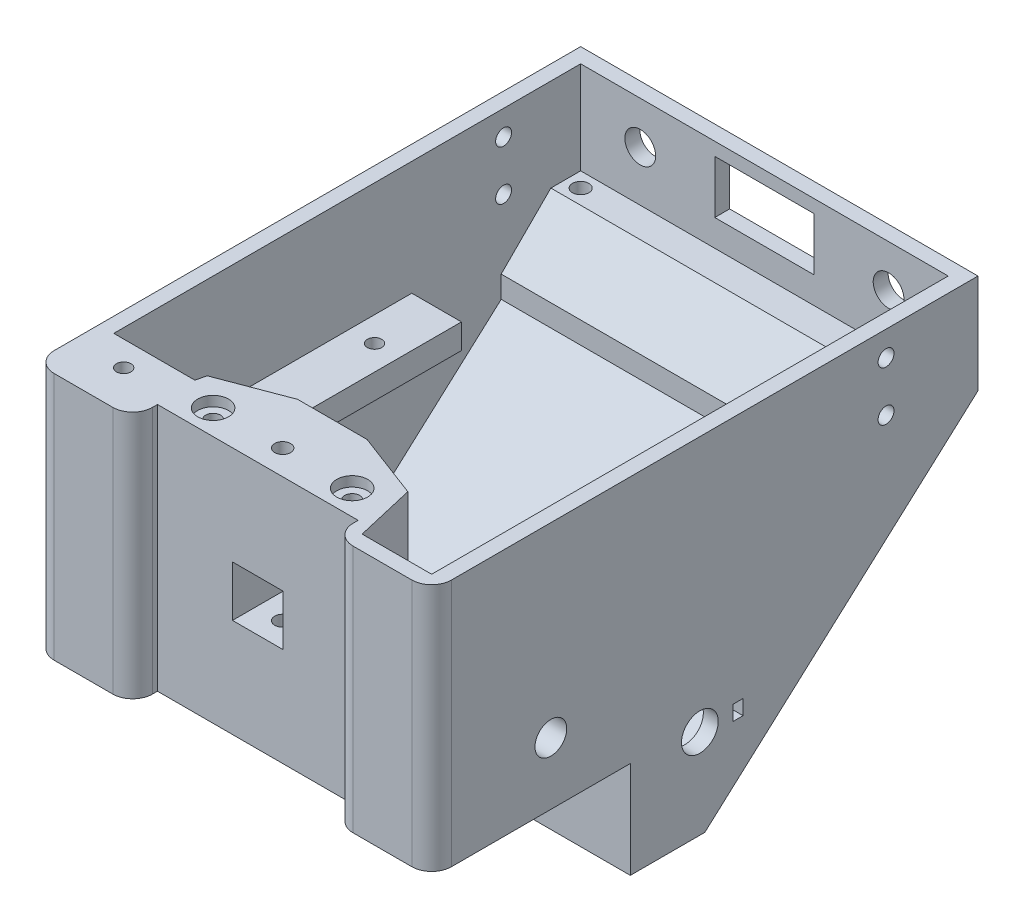
from build123d import *

# Parameters (mm, degrees)
BOSS_EXTRUDE1_DEPTH      = 80
SHELL1_T                 = -3
SKETCH3_W                = 46
SKETCH3_H                = 47
BOSS_EXTRUDE2_DEPTH      = 17
SKETCH4_W                = 10.2
SKETCH4_H                = 10.2
CUT_EXTRUDE1_DEPTH       = 20
SKETCH6_W                = 15
SKETCH6_H                = 12.8
CUT_EXTRUDE2_DEPTH       = 3
SKETCH7_W                = 40.4
SKETCH7_H                = 50
CUT_EXTRUDE3_DEPTH       = 5
FILLET1_R                = 4
CUT_EXTRUDE7_DEPTH       = 47
SKETCH13_R               = 1.5
CUT_EXTRUDE8_DEPTH       = 25
SKETCH14_R               = 3.1
CUT_EXTRUDE9_DEPTH       = 2
SKETCH17_W               = 45
SKETCH17_H               = 5
BOSS_EXTRUDE5_DEPTH      = 74
CUT_EXTRUDE10_REACH      = 126.093
SKETCH18_W               = 54
SKETCH18_H               = 45
CUT_EXTRUDE11_REACH      = 126.093
SKETCH19_R               = 1.45
BOSS_EXTRUDE6_DEPTH      = 47
SKETCH22_R               = 1.45
CUT_EXTRUDE12_DEPTH      = 135.415364765
CUT_EXTRUDE13_REACH      = 126.857
SKETCH24_R               = 3.7
SKETCH24_W               = 2
SKETCH24_H               = 3
BOSS_EXTRUDE7_DEPTH      = 74
SKETCH27_R               = 1.65
CUT_EXTRUDE14_DEPTH      = 10
CUT_EXTRUDE15_START      = -3
CUT_EXTRUDE15_DEPTH      = 32
CUT_EXTRUDE16_DEPTH      = 30
BOSS_EXTRUDE8_DEPTH      = 20
SKETCH31_R               = 1.5
CUT_EXTRUDE17_DEPTH      = 123.649786567
CUT_EXTRUDE18_DEPTH      = 15
CUT_EXTRUDE19_REACH      = 126.093
SKETCH33_W               = 10
SKETCH33_H               = 5
SKETCH34_R               = 1.6
CUT_EXTRUDE20_DEPTH      = 135.415364765
CUT_EXTRUDE22_DEPTH      = 14
CUT_EXTRUDE23_REACH      = 126.857
SKETCH37_R               = 3.2
SKETCH38_W               = 10
SKETCH38_H               = 18.980735551
SKETCH38_R               = 3.2
BOSS_EXTRUDE9_DEPTH      = 3
CUT_EXTRUDE24_REACH      = 124.956
SKETCH40_R               = 3.7
SKETCH40_W               = 2
SKETCH40_H               = 3
SKETCH41_R               = 1.6
CUT_EXTRUDE25_DEPTH      = 123.956316006
CUT_EXTRUDE25_DEPTH_BACK = 123.956316006
SKETCH43_W               = 20
SKETCH43_H               = 10.67
CUT_EXTRUDE26_DEPTH      = 3
CHAMFER1_SIZE            = 10
SKETCH44_R               = 3.1
CUT_EXTRUDE27_DEPTH      = 143.134986308


with BuildPart() as part:
    # Sketch2 → Boss-Extrude1 (new body)
    with BuildSketch(Plane(origin=(0, 0, 0), x_dir=(0, 0, -1), z_dir=(1, 0, 0))):
        Polygon((-27.320490368, 20.998248687), (-27.320490368, -29.001751313), (12.679509632, -29.001751313), (12.679509632, -48.511383538), (27.679509632, -48.511383538), (82.679509632, 0.998248687), (82.679509632, 20.998248687), align=None)
    extrude(amount=BOSS_EXTRUDE1_DEPTH)

    # Shell1
    shell1_openings = [part.faces().sort_by_distance(p)[0] for p in [
        (40, 20.998248687, -27.679509632),
    ]]
    offset(amount=SHELL1_T, openings=shell1_openings, kind=Kind.INTERSECTION)

    # Sketch3 → Boss-Extrude2 (add)
    with BuildSketch(Plane(origin=(0, 0, 24.320490368), x_dir=(-1, 0, 0), z_dir=(0, 0, -1))):
        with Locations((-40, -2.501751313)):
            Rectangle(SKETCH3_W, SKETCH3_H)
    extrude(amount=BOSS_EXTRUDE2_DEPTH)

    # Sketch4 → Cut-Extrude1 (cut)
    with BuildSketch(Plane.XY.offset(27.320490368)):
        with Locations((40, -4.001751313)):
            Rectangle(SKETCH4_W, SKETCH4_H)
    extrude(amount=-CUT_EXTRUDE1_DEPTH, mode=Mode.SUBTRACT)

    # Sketch6 → Cut-Extrude2 (cut)
    with BuildSketch(Plane.XZ.offset(29.001751313)):
        with Locations((40, 0.920490368)):
            Rectangle(SKETCH6_W, SKETCH6_H)
    extrude(amount=-CUT_EXTRUDE2_DEPTH, mode=Mode.SUBTRACT)

    # Sketch7 → Cut-Extrude3 (cut)
    with BuildSketch(Plane.XY.offset(27.320490368)):
        with Locations((40, -4.001751313)):
            Rectangle(SKETCH7_W, SKETCH7_H)
    extrude(amount=-CUT_EXTRUDE3_DEPTH, mode=Mode.SUBTRACT)

    # Fillet1
    fillet1_edges = [part.edges().sort_by_distance(p)[0] for p in [
        (80, -4.001751313, 27.320490368),
        (19.8, -4.001751313, 27.320490368),
        (0, -4.001751313, 27.320490368),
        (60.2, -4.001751313, 27.320490368),
    ]]
    fillet(fillet1_edges, radius=FILLET1_R)

    # Sketch12 → Cut-Extrude7 (cut)
    with BuildSketch(Plane(origin=(0, 20.998248687, 0), x_dir=(1, 0, 0), z_dir=(0, 1, 0))):
        Polygon((33, -7.320490368), (19.8, -12.320490368), (17, -24.320490368), (17, -7.320490368), align=None)
        Polygon((47, -7.320490368), (63, -7.320490368), (63, -24.320490368), (60.2, -12.320490368), align=None)
    extrude(amount=-CUT_EXTRUDE7_DEPTH, mode=Mode.SUBTRACT)

    # Sketch13 → Cut-Extrude8 (cut)
    with BuildSketch(Plane(origin=(0, 20.998248687, 0), x_dir=(1, 0, 0), z_dir=(0, 1, 0))):
        with Locations(Location((26, -17.320490368, 0), (0, 0, 270))):
            Circle(SKETCH13_R)
        with Locations(Location((54, -17.320490368, 0), (0, 0, 270))):
            Circle(SKETCH13_R)
    extrude(amount=-CUT_EXTRUDE8_DEPTH, mode=Mode.SUBTRACT)

    # Sketch14 → Cut-Extrude9 (cut)
    with BuildSketch(Plane(origin=(0, 20.998248687, 0), x_dir=(1, 0, 0), z_dir=(0, 1, 0))):
        with Locations(Location((26, -17.320490368, 0), (0, 0, 270))):
            Circle(SKETCH14_R)
        with Locations(Location((54, -17.320490368, 0), (0, 0, 270))):
            Circle(SKETCH14_R)
    extrude(amount=-CUT_EXTRUDE9_DEPTH, mode=Mode.SUBTRACT)

    # Sketch17 → Boss-Extrude5 (add)
    with BuildSketch(Plane.ZY.offset(-77)):
        with Locations((-23.179509632, -4.501751313)):
            Rectangle(SKETCH17_W, SKETCH17_H)
    extrude(amount=BOSS_EXTRUDE5_DEPTH)

    # Sketch18 → Cut-Extrude10 (cut, up to next)
    with BuildSketch(Plane(origin=(0, -2.001751313, 0), x_dir=(1, 0, 0), z_dir=(0, 1, 0)), mode=Mode.PRIVATE) as cut_extrude10_sk1:
        with Locations((40, 23.179509632)):
            Rectangle(SKETCH18_W, SKETCH18_H)
    cut_extrude10_tool1 = extrude(cut_extrude10_sk1.sketch, amount=-CUT_EXTRUDE10_REACH, mode=Mode.PRIVATE) & part.part
    add(cut_extrude10_tool1.solids().sort_by_distance((40, -2.001751, -23.17951))[0], mode=Mode.SUBTRACT)

    # Sketch19 → Cut-Extrude11 (cut, up to next)
    with BuildSketch(Plane(origin=(0, -2.001751313, 0), x_dir=(1, 0, 0), z_dir=(0, 1, 0)), mode=Mode.PRIVATE) as cut_extrude11_sk1:
        with Locations(Location((72, 37.179509632, 0), (0, 0, 270))):
            Circle(SKETCH19_R)
    cut_extrude11_tool1 = extrude(cut_extrude11_sk1.sketch, amount=-CUT_EXTRUDE11_REACH, mode=Mode.PRIVATE) & part.part
    # Sketch19 → Cut-Extrude11 (cut, up to next)
    with BuildSketch(Plane(origin=(0, -2.001751313, 0), x_dir=(1, 0, 0), z_dir=(0, 1, 0)), mode=Mode.PRIVATE) as cut_extrude11_sk2:
        with Locations(Location((72, 6.179509632, 0), (0, 0, 270))):
            Circle(SKETCH19_R)
    cut_extrude11_tool2 = extrude(cut_extrude11_sk2.sketch, amount=-CUT_EXTRUDE11_REACH, mode=Mode.PRIVATE) & part.part
    # Sketch19 → Cut-Extrude11 (cut, up to next)
    with BuildSketch(Plane(origin=(0, -2.001751313, 0), x_dir=(1, 0, 0), z_dir=(0, 1, 0)), mode=Mode.PRIVATE) as cut_extrude11_sk3:
        with Locations(Location((8, 33.179509632, 0), (0, 0, 270))):
            Circle(SKETCH19_R)
    cut_extrude11_tool3 = extrude(cut_extrude11_sk3.sketch, amount=-CUT_EXTRUDE11_REACH, mode=Mode.PRIVATE) & part.part
    # Sketch19 → Cut-Extrude11 (cut, up to next)
    with BuildSketch(Plane(origin=(0, -2.001751313, 0), x_dir=(1, 0, 0), z_dir=(0, 1, 0)), mode=Mode.PRIVATE) as cut_extrude11_sk4:
        with Locations(Location((8, 6.179509632, 0), (0, 0, 270))):
            Circle(SKETCH19_R)
    cut_extrude11_tool4 = extrude(cut_extrude11_sk4.sketch, amount=-CUT_EXTRUDE11_REACH, mode=Mode.PRIVATE) & part.part
    add(cut_extrude11_tool1.solids().sort_by_distance((72, -2.001751, -37.17951))[0], mode=Mode.SUBTRACT)
    add(cut_extrude11_tool2.solids().sort_by_distance((72, -2.001751, -6.17951))[0], mode=Mode.SUBTRACT)
    add(cut_extrude11_tool3.solids().sort_by_distance((8, -2.001751, -33.17951))[0], mode=Mode.SUBTRACT)
    add(cut_extrude11_tool4.solids().sort_by_distance((8, -2.001751, -6.17951))[0], mode=Mode.SUBTRACT)

    # Sketch21 → Boss-Extrude6 (add)
    with BuildSketch(Plane(origin=(0, -26.001751313, 0), x_dir=(1, 0, 0), z_dir=(0, 1, 0))):
        Polygon((3, -24.320490368), (3, -14.320490368), (19.333333333, -14.320490368), (17, -24.320490368), align=None)
    extrude(amount=BOSS_EXTRUDE6_DEPTH)

    # Sketch22 → Cut-Extrude12 (cut, through all)
    with BuildSketch(Plane(origin=(0, 20.998248687, 0), x_dir=(1, 0, 0), z_dir=(0, 1, 0))):
        with Locations(Location((10, -19.320490368, 0), (0, 0, 270))):
            Circle(SKETCH22_R)
    extrude(amount=-CUT_EXTRUDE12_DEPTH, mode=Mode.SUBTRACT)

    # Sketch24 → Cut-Extrude13 (cut, up to next)
    with BuildSketch(Plane(origin=(80, 0, 0), x_dir=(0, 0, -1), z_dir=(1, 0, 0)), mode=Mode.PRIVATE) as cut_extrude13_sk1:
        with Locations((26.679509632, -30.511383538)):
            Circle(SKETCH24_R)
    cut_extrude13_tool1 = extrude(cut_extrude13_sk1.sketch, amount=-CUT_EXTRUDE13_REACH, mode=Mode.PRIVATE) & part.part
    # Sketch24 → Cut-Extrude13 (cut, up to next)
    with BuildSketch(Plane(origin=(80, 0, 0), x_dir=(0, 0, -1), z_dir=(1, 0, 0)), mode=Mode.PRIVATE) as cut_extrude13_sk2:
        with Locations((34.379509632, -30.511383538)):
            Rectangle(SKETCH24_W, SKETCH24_H)
    cut_extrude13_tool2 = extrude(cut_extrude13_sk2.sketch, amount=-CUT_EXTRUDE13_REACH, mode=Mode.PRIVATE) & part.part
    add(cut_extrude13_tool1.solids().sort_by_distance((80, -30.511384, -26.67951))[0], mode=Mode.SUBTRACT)
    add(cut_extrude13_tool2.solids().sort_by_distance((80, -30.511384, -34.37951))[0], mode=Mode.SUBTRACT)

    # Sketch26 → Boss-Extrude7 (add)
    with BuildSketch(Plane(origin=(3, 0, 0), x_dir=(0, 0, -1), z_dir=(1, 0, 0))):
        Polygon((79.679509632, 2.334161996), (63.679509632, 2.334161996), (63.679509632, -12.068640106), align=None)
    extrude(amount=BOSS_EXTRUDE7_DEPTH)

    # Sketch27 → Cut-Extrude14 (cut)
    with BuildSketch(Plane(origin=(0, 2.334161996, 0), x_dir=(1, 0, 0), z_dir=(0, 1, 0))):
        with Locations(Location((6, 76.679509632, 0), (0, 0, 270))):
            Circle(SKETCH27_R)
        with Locations(Location((74, 76.679509632, 0), (0, 0, 270))):
            Circle(SKETCH27_R)
    extrude(amount=-CUT_EXTRUDE14_DEPTH, mode=Mode.SUBTRACT)

    # Sketch28 → Cut-Extrude15 (cut)
    with BuildSketch(Plane(origin=(0, 2.334161996, 0), x_dir=(1, 0, 0), z_dir=(0, 1, 0)).offset(CUT_EXTRUDE15_START)):
        Polygon((74, 79.929509632), (71.185417438, 78.304509632), (71.185417438, 75.054509632), (74, 73.429509632), (76.814582562, 75.054509632), (76.814582562, 78.304509632), align=None)
        Polygon((6, 73.429509632), (8.814582562, 75.054509632), (8.814582562, 78.304509632), (6, 79.929509632), (3.185417438, 78.304509632), (3.185417438, 75.054509632), align=None)
    extrude(amount=-CUT_EXTRUDE15_DEPTH, mode=Mode.SUBTRACT)

    # Sketch29 → Cut-Extrude16 (cut)
    with BuildSketch(Plane.XZ.offset(29.001751313)):
        Polygon((7.185417438, 17.695490368), (10, 16.070490368), (12.814582562, 17.695490368), (12.814582562, 20.945490368), (10, 22.570490368), (7.185417438, 20.945490368), align=None)
    extrude(amount=-CUT_EXTRUDE16_DEPTH, mode=Mode.SUBTRACT)

    # Sketch30 → Boss-Extrude8 (add)
    with BuildSketch(Plane(origin=(0, -26.001751313, 0), x_dir=(1, 0, 0), z_dir=(0, 1, 0))):
        Polygon((77, -24.320490368), (63, -24.320490368), (60.2, -12.320490368), (77, -12.320490368), align=None)
    extrude(amount=BOSS_EXTRUDE8_DEPTH)

    # Sketch31 → Cut-Extrude17 (cut, through all)
    with BuildSketch(Plane(origin=(0, -6.001751313, 0), x_dir=(1, 0, 0), z_dir=(0, 1, 0))):
        with Locations(Location((72, -21.320490368, 0), (0, 0, 270))):
            Circle(SKETCH31_R)
    extrude(amount=-CUT_EXTRUDE17_DEPTH, mode=Mode.SUBTRACT)

    # Sketch32 → Cut-Extrude18 (cut)
    with BuildSketch(Plane.XZ.offset(29.001751313)):
        Polygon((72, 24.570490368), (69.185417438, 22.945490368), (69.185417438, 19.695490368), (72, 18.070490368), (74.814582562, 19.695490368), (74.814582562, 22.945490368), align=None)
    extrude(amount=-CUT_EXTRUDE18_DEPTH, mode=Mode.SUBTRACT)

    # Sketch33 → Cut-Extrude19 (cut, up to next)
    with BuildSketch(Plane(origin=(0, -2.001751313, 0), x_dir=(1, 0, 0), z_dir=(0, 1, 0)), mode=Mode.PRIVATE) as cut_extrude19_sk1:
        with Locations((72, 43.179509632)):
            Rectangle(SKETCH33_W, SKETCH33_H)
    cut_extrude19_tool1 = extrude(cut_extrude19_sk1.sketch, amount=-CUT_EXTRUDE19_REACH, mode=Mode.PRIVATE) & part.part
    add(cut_extrude19_tool1.solids().sort_by_distance((72, -2.001751, -43.17951))[0], mode=Mode.SUBTRACT)

    # Sketch34 → Cut-Extrude20 (cut, through all)
    with BuildSketch(Plane(origin=(0, 20.998248687, 0), x_dir=(1, 0, 0), z_dir=(0, 1, 0))):
        with Locations(Location((40, -17.320490368, 0), (0, 0, 270))):
            Circle(SKETCH34_R)
    extrude(amount=-CUT_EXTRUDE20_DEPTH, mode=Mode.SUBTRACT)

    # Sketch36 → Cut-Extrude22 (cut)
    with BuildSketch(Plane.XZ.offset(29.001751313)):
        Polygon((38.375, 20.13507293), (36.75, 17.320490368), (38.375, 14.505907805), (41.625, 14.505907805), (43.25, 17.320490368), (41.625, 20.13507293), align=None)
    extrude(amount=-CUT_EXTRUDE22_DEPTH, mode=Mode.SUBTRACT)

    # Sketch37 → Cut-Extrude23 (cut, up to next)
    with BuildSketch(Plane(origin=(80, 0, 0), x_dir=(0, 0, -1), z_dir=(1, 0, 0)), mode=Mode.PRIVATE) as cut_extrude23_sk1:
        with Locations((-3.320490368, -16.511383538)):
            Circle(SKETCH37_R)
    cut_extrude23_tool1 = extrude(cut_extrude23_sk1.sketch, amount=-CUT_EXTRUDE23_REACH, mode=Mode.PRIVATE) & part.part
    add(cut_extrude23_tool1.solids().sort_by_distance((80, -16.511384, 3.32049))[0], mode=Mode.SUBTRACT)

    # Sketch38 → Boss-Extrude9 (add)
    with BuildSketch(Plane.ZY.offset(-77)):
        with Locations((3.320490368, -16.511383538)):
            Rectangle(SKETCH38_W, SKETCH38_H)
        with Locations(Location((3.320490368, -16.511383538, 0), (0, 0, 180))):
            Circle(SKETCH38_R, mode=Mode.SUBTRACT)
    extrude(amount=BOSS_EXTRUDE9_DEPTH)

    # Sketch40 → Cut-Extrude24 (cut, up to next)
    with BuildSketch(Plane(origin=(3, 0, 0), x_dir=(0, 0, -1), z_dir=(1, 0, 0)), mode=Mode.PRIVATE) as cut_extrude24_sk1:
        with Locations((26.679509632, -30.511383538)):
            Circle(SKETCH40_R)
    cut_extrude24_tool1 = extrude(cut_extrude24_sk1.sketch, amount=-CUT_EXTRUDE24_REACH, mode=Mode.PRIVATE) & part.part
    # Sketch40 → Cut-Extrude24 (cut, up to next)
    with BuildSketch(Plane(origin=(3, 0, 0), x_dir=(0, 0, -1), z_dir=(1, 0, 0)), mode=Mode.PRIVATE) as cut_extrude24_sk2:
        with Locations((18.979509632, -30.511383538)):
            Rectangle(SKETCH40_W, SKETCH40_H)
    cut_extrude24_tool2 = extrude(cut_extrude24_sk2.sketch, amount=-CUT_EXTRUDE24_REACH, mode=Mode.PRIVATE) & part.part
    add(cut_extrude24_tool1.solids().sort_by_distance((3, -30.511384, -26.67951))[0], mode=Mode.SUBTRACT)
    add(cut_extrude24_tool2.solids().sort_by_distance((3, -30.511384, -18.97951))[0], mode=Mode.SUBTRACT)

    # Sketch41 → Cut-Extrude25 (cut, two sides)
    with BuildSketch(Plane.ZY.offset(-77)) as cut_extrude25_sk:
        with Locations((-64.162210742, 15.998248687)):
            Circle(SKETCH41_R)
        with Locations((-64.162210742, 5.998248687)):
            Circle(SKETCH41_R)
    extrude(amount=CUT_EXTRUDE25_DEPTH, mode=Mode.SUBTRACT)
    extrude(cut_extrude25_sk.sketch, amount=-CUT_EXTRUDE25_DEPTH_BACK, mode=Mode.SUBTRACT)

    # Sketch43 → Cut-Extrude26 (cut)
    with BuildSketch(Plane.XY.offset(-79.679509632)):
        with Locations((40, 13.033248687)):
            Rectangle(SKETCH43_W, SKETCH43_H)
    extrude(amount=-CUT_EXTRUDE26_DEPTH, mode=Mode.SUBTRACT)

    # Chamfer1
    chamfer1_edges = [part.edges().sort_by_distance(p)[0] for p in [
        (40, 2.334161996, -63.679509632),
    ]]
    chamfer(chamfer1_edges, length=CHAMFER1_SIZE)

    # Sketch44 → Cut-Extrude27 (cut, through all)
    with BuildSketch(Plane.XY.offset(-79.679509632)):
        with Locations((65, 12.468248687)):
            Circle(SKETCH44_R)
        with Locations((15, 12.468248687)):
            Circle(SKETCH44_R)
    extrude(amount=-CUT_EXTRUDE27_DEPTH, mode=Mode.SUBTRACT)


solid = part.part
